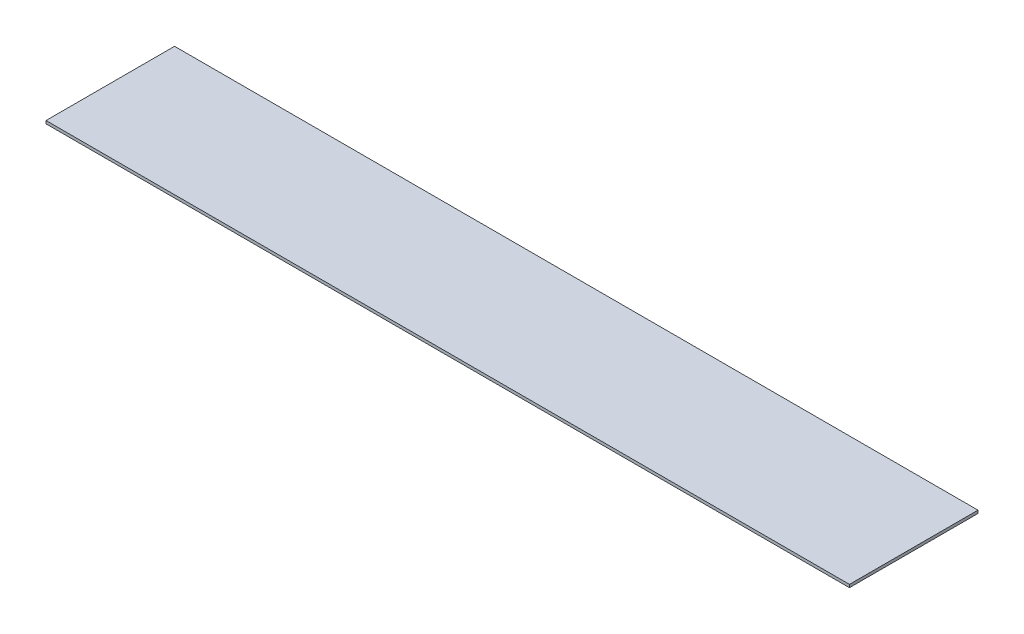
from build123d import *

# Parameters (mm, degrees)
SKETCH1_W           = 50
SKETCH1_H           = 8
BOSS_EXTRUDE1_DEPTH = 0.18


with BuildPart() as part:
    # Sketch1 → Boss-Extrude1 (new body)
    with BuildSketch(Plane(origin=(0, 0, 0), x_dir=(1, 0, 0), z_dir=(0, 1, 0))):
        Rectangle(SKETCH1_W, SKETCH1_H)
    extrude(amount=BOSS_EXTRUDE1_DEPTH)


solid = part.part
